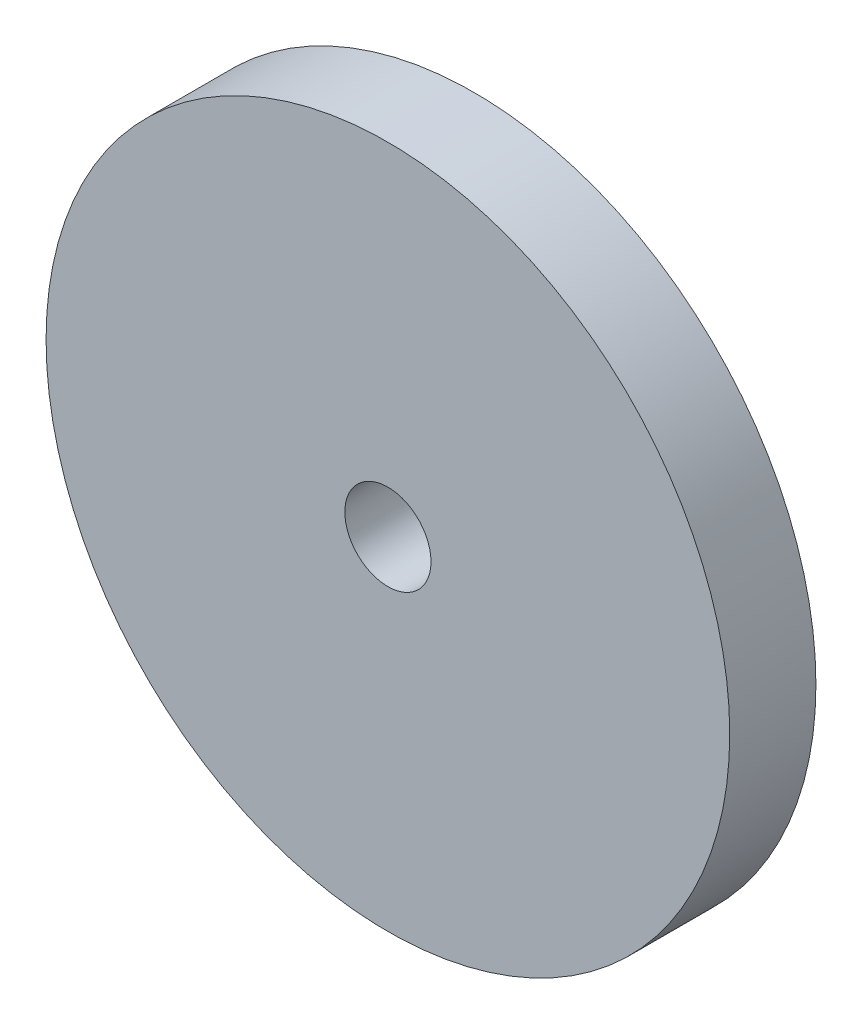
from build123d import *

# Parameters (mm, degrees)
MODEL_R                 = 11.9
MODEL_R_2               = 1.5
SALIENTE_EXTRUIR1_DEPTH = 3


with BuildPart() as part:
    # Model → Saliente-Extruir1 (new body)
    with BuildSketch(Plane.XY):
        with Locations((55, 31)):
            Circle(MODEL_R)
        with Locations((55, 31)):
            Circle(MODEL_R_2, mode=Mode.SUBTRACT)
    extrude(amount=SALIENTE_EXTRUIR1_DEPTH)


solid = part.part
